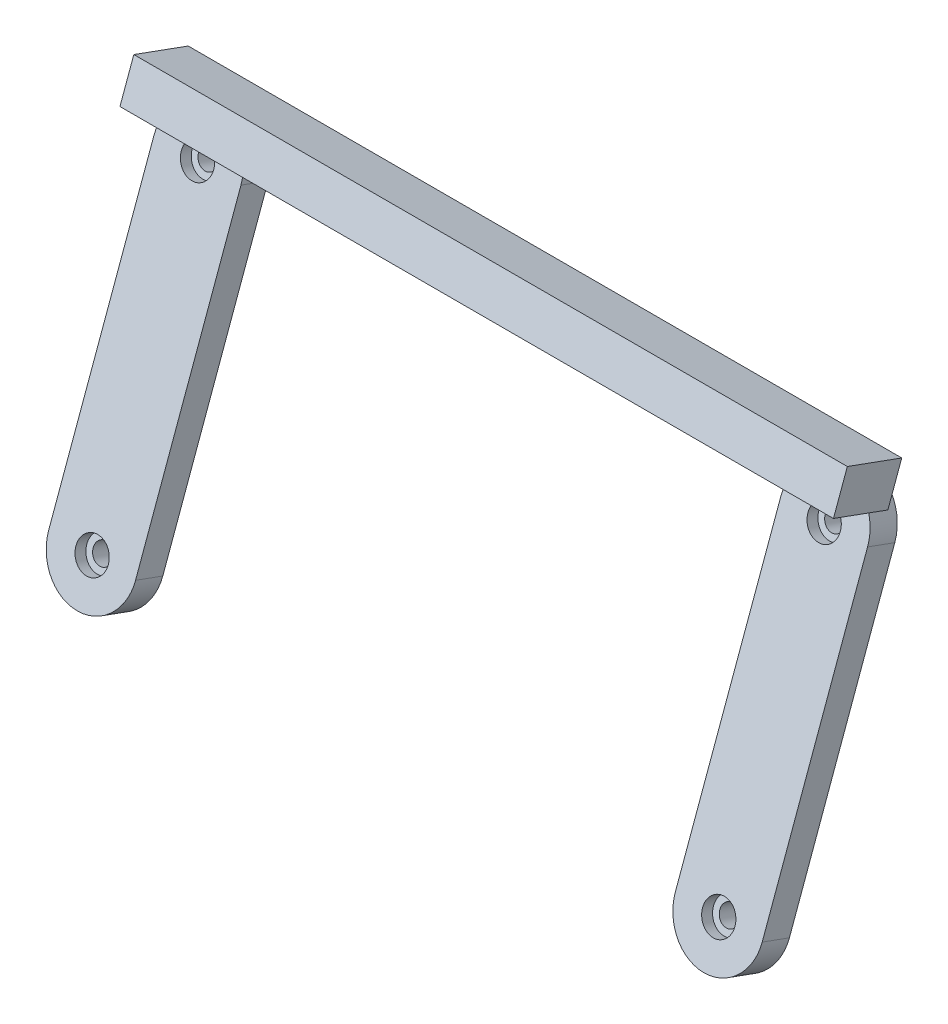
from build123d import *

# Parameters (mm, degrees)
ESQUISSE3_R          = 7.5
ESQUISSE3_R_2        = 2.8
BOSS_EXTRU_1_DEPTH   = 2
BOSS_EXTRU_1_2_DEPTH = 2
BOSS_EXTRU_1_3_DEPTH = 2
BOSS_EXTRU_1_4_DEPTH = 2
ESQUISSE4_R          = 7.5
ESQUISSE4_R_2        = 1.7
BOSS_EXTRU_2_DEPTH   = 3
BOSS_EXTRU_3_DEPTH   = 5
BOSS_EXTRU_4_START   = -2
ESQUISSE6_W          = 123.2
ESQUISSE6_H          = 7
BOSS_EXTRU_4_DEPTH   = 10


with BuildPart() as part:
    # Esquisse3 → Boss.-Extru.1 (new body)
    with BuildSketch(Plane(origin=(0, 0, 0), x_dir=(1, 0, 0), z_dir=(0, 0.342020143, 0.939692621))):
        with Locations((-54.1, 26.6)):
            Circle(ESQUISSE3_R)
        with Locations((-54.1, 26.6)):
            Circle(ESQUISSE3_R_2, mode=Mode.SUBTRACT)
    extrude(amount=BOSS_EXTRU_1_DEPTH)



with BuildPart() as body_2:
    # Esquisse3 → Boss.-Extru.1 2 (new body)
    with BuildSketch(Plane(origin=(0, 0, 0), x_dir=(1, 0, 0), z_dir=(0, 0.342020143, 0.939692621))):
        with Locations((54.1, 26.6)):
            Circle(ESQUISSE3_R)
        with Locations((54.1, 26.6)):
            Circle(ESQUISSE3_R_2, mode=Mode.SUBTRACT)
    extrude(amount=BOSS_EXTRU_1_2_DEPTH)


with BuildPart() as body_3:
    # Esquisse3 → Boss.-Extru.1 3 (new body)
    with BuildSketch(Plane(origin=(0, 0, 0), x_dir=(1, 0, 0), z_dir=(0, 0.342020143, 0.939692621))):
        with Locations((54.1, -26.6)):
            Circle(ESQUISSE3_R)
        with Locations((54.1, -26.6)):
            Circle(ESQUISSE3_R_2, mode=Mode.SUBTRACT)
    extrude(amount=BOSS_EXTRU_1_3_DEPTH)


with BuildPart() as body_4:
    # Esquisse3 → Boss.-Extru.1 4 (new body)
    with BuildSketch(Plane(origin=(0, 0, 0), x_dir=(1, 0, 0), z_dir=(0, 0.342020143, 0.939692621))):
        with Locations((-54.1, -26.6)):
            Circle(ESQUISSE3_R)
        with Locations((-54.1, -26.6)):
            Circle(ESQUISSE3_R_2, mode=Mode.SUBTRACT)
    extrude(amount=BOSS_EXTRU_1_4_DEPTH)


with BuildPart() as part_1:
    add(part.part)

    add(body_2.part)  # Boss.-Extru.2 merges body 2

    add(body_3.part)  # Boss.-Extru.2 merges body 3

    add(body_4.part)  # Boss.-Extru.2 merges body 4
    # Esquisse4 → Boss.-Extru.2 (add)
    with BuildSketch(Plane(origin=(0, 0, 0), x_dir=(-1, 0, 0), z_dir=(0, -0.342020143, -0.939692621))):
        with Locations((-54.1, 26.6)):
            Circle(ESQUISSE4_R)
        with Locations((-54.1, 26.6)):
            Circle(ESQUISSE4_R_2, mode=Mode.SUBTRACT)
        with Locations((54.1, 26.6)):
            Circle(ESQUISSE4_R)
        with Locations((54.1, 26.6)):
            Circle(ESQUISSE4_R_2, mode=Mode.SUBTRACT)
        with Locations((54.1, -26.6)):
            Circle(ESQUISSE4_R)
        with Locations((54.1, -26.6)):
            Circle(ESQUISSE4_R_2, mode=Mode.SUBTRACT)
        with Locations((-54.1, -26.6)):
            Circle(ESQUISSE4_R)
        with Locations((-54.1, -26.6)):
            Circle(ESQUISSE4_R_2, mode=Mode.SUBTRACT)
    extrude(amount=BOSS_EXTRU_2_DEPTH)

    # Esquisse5 → Boss.-Extru.3 (add)
    with BuildSketch(Plane(origin=(0, -1.02606043, -2.819077862), x_dir=(-1, 0, 0), z_dir=(0, -0.342020143, -0.939692621))):
        with BuildLine():
            Line((-61.6, 26.6), (-61.6, -26.6))
            ThreePointArc((-61.6, -26.6), (-54.1, -19.1), (-46.6, -26.6))
            Line((-46.6, -26.6), (-46.6, 26.6))
            ThreePointArc((-46.6, 26.6), (-54.1, 19.1), (-61.6, 26.6))
        make_face()
        with BuildLine():
            Line((61.6, 26.6), (61.6, -26.6))
            ThreePointArc((61.6, -26.6), (54.1, -19.1), (46.6, -26.6))
            Line((46.6, -26.6), (46.6, 26.6))
            ThreePointArc((46.6, 26.6), (54.1, 19.1), (61.6, 26.6))
        make_face()
    extrude(amount=-BOSS_EXTRU_3_DEPTH)

    # Esquisse6 → Boss.-Extru.4 (add)
    with BuildSketch(Plane(origin=(0, 0.684040287, 1.879385242), x_dir=(1, 0, 0), z_dir=(0, 0.342020143, 0.939692621)).offset(BOSS_EXTRU_4_START)):
        with Locations((0, 34.85)):
            Rectangle(ESQUISSE6_W, ESQUISSE6_H)
    extrude(amount=BOSS_EXTRU_4_DEPTH)


solid = part_1.part
